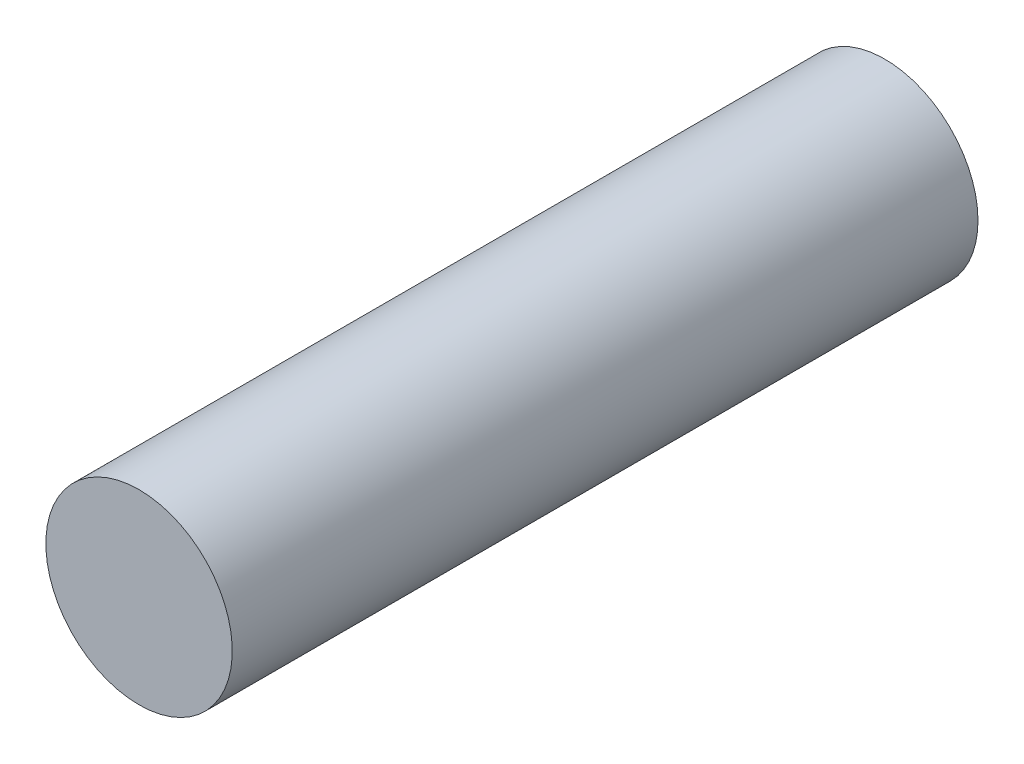
from build123d import *

# Parameters (mm, degrees)
BOSS_EXTRUDE1_START = -7.38
SKETCH1_R           = 1
BOSS_EXTRUDE1_DEPTH = 8


with BuildPart() as part:
    # Sketch1 → Boss-Extrude1 (new body)
    with BuildSketch(Plane.XY.offset(BOSS_EXTRUDE1_START)):
        Circle(SKETCH1_R)
    extrude(amount=BOSS_EXTRUDE1_DEPTH)


solid = part.part
